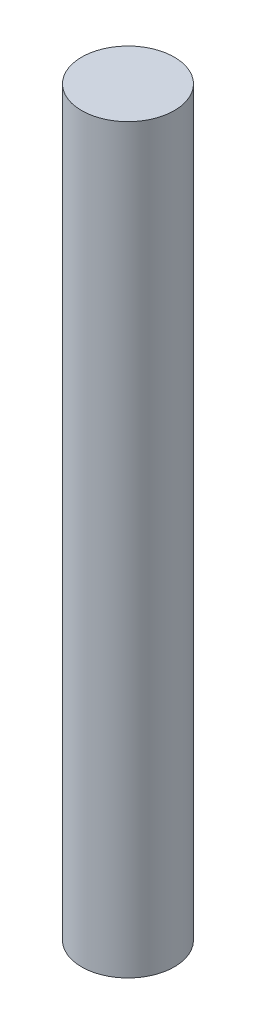
from build123d import *

# Parameters (mm, degrees)
SKETCH1_R           = 1.5875
BOSS_EXTRUDE1_DEPTH = 25.4


with BuildPart() as part:
    # Sketch1 → Boss-Extrude1 (new body)
    with BuildSketch(Plane(origin=(0, 0, 0), x_dir=(1, 0, 0), z_dir=(0, 1, 0))):
        Circle(SKETCH1_R)
    extrude(amount=-BOSS_EXTRUDE1_DEPTH)


solid = part.part
